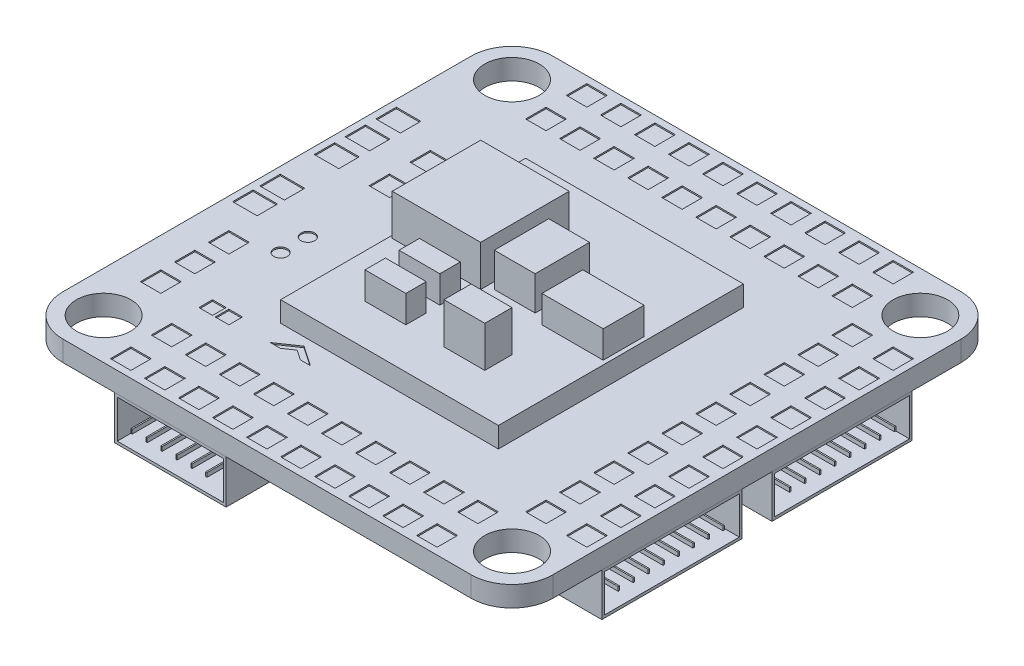
from build123d import *

# Parameters (mm, degrees)
SKETCH1_R                = 2
BOSS_EXTRUDE1_DEPTH      = 1.5
SKETCH2_W                = 16
SKETCH2_H                = 18
BOSS_EXTRUDE2_DEPTH      = 1.5
SKETCH3_W                = 6.5
SKETCH3_H                = 6.5
BOSS_EXTRUDE3_DEPTH      = 3
SKETCH4_W                = 3
SKETCH4_H                = 1.5
BOSS_EXTRUDE4_DEPTH      = 2
SKETCH5_W                = 3
SKETCH5_H                = 2
BOSS_EXTRUDE5_DEPTH      = 3
SKETCH6_W                = 3
SKETCH6_H                = 4
BOSS_EXTRUDE6_DEPTH      = 2.5
SKETCH7_W                = 4.5
SKETCH7_H                = 3
BOSS_EXTRUDE7_DEPTH      = 2
CUT_EXTRUDE1_DEPTH       = 0.1
SKETCH9_R                = 0.5
SKETCH9_W                = 1.5
SKETCH9_H                = 1.5
SKETCH9_W_2              = 1
SKETCH9_H_2              = 1
SKETCH9_W_3              = 1.8
CUT_EXTRUDE2_DEPTH       = 0.1
BOSS_EXTRUDE8_DEPTH      = 1.5
BOSS_EXTRUDE8_DEPTH_BACK = 5.7
CUT_EXTRUDE3_DEPTH       = 6
SKETCH15_W               = 2.5
SKETCH15_H               = 4.5
BOSS_EXTRUDE9_DEPTH      = 2
SKETCH16_W               = 2
SKETCH16_H               = 1
BOSS_EXTRUDE10_DEPTH     = 1
SKETCH17_W               = 8.2
SKETCH17_H               = 3.2
BOSS_EXTRUDE11_DEPTH     = 4.5
SKETCH18_W               = 7.8
SKETCH18_H               = 2.8
SKETCH18_W_2             = 0.1
SKETCH18_H_2             = 0.3
CUT_EXTRUDE4_DEPTH       = 4
SKETCH19_W               = 10.3
SKETCH19_H               = 3.1557765
BOSS_EXTRUDE12_DEPTH     = 4.3
BOSS_EXTRUDE12_2_DEPTH   = 4.3
SKETCH20_W               = 9.9
SKETCH20_H               = 2.7557765
SKETCH20_W_2             = 0.1
SKETCH20_H_2             = 0.3
CUT_EXTRUDE5_DEPTH       = 3.5


with BuildPart() as part:
    # Sketch1 → Boss-Extrude1 (new body)
    with BuildSketch(Plane(origin=(0, 0, 0), x_dir=(1, 0, 0), z_dir=(0, 1, 0))):
        with BuildLine():
            Line((-15, 18), (15, 18))
            ThreePointArc((15, 18), (17.121320344, 17.121320344), (18, 15))
            Line((18, 15), (18, -15))
            ThreePointArc((18, -15), (17.121320344, -17.121320344), (15, -18))
            Line((15, -18), (-15, -18))
            ThreePointArc((-15, -18), (-17.121320344, -17.121320344), (-18, -15))
            Line((-18, -15), (-18, 15))
            ThreePointArc((-18, 15), (-17.121320344, 17.121320344), (-15, 18))
        make_face()
        with Locations((-15, 15)):
            Circle(SKETCH1_R, mode=Mode.SUBTRACT)
        with Locations((15, 15)):
            Circle(SKETCH1_R, mode=Mode.SUBTRACT)
        with Locations((15, -15)):
            Circle(SKETCH1_R, mode=Mode.SUBTRACT)
        with Locations((-15, -15)):
            Circle(SKETCH1_R, mode=Mode.SUBTRACT)
    extrude(amount=BOSS_EXTRUDE1_DEPTH)

    # Sketch2 → Boss-Extrude2 (add)
    with BuildSketch(Plane(origin=(0, 1.5, 0), x_dir=(1, 0, 0), z_dir=(0, 1, 0))):
        Rectangle(SKETCH2_W, SKETCH2_H)
    extrude(amount=BOSS_EXTRUDE2_DEPTH)

    # Sketch3 → Boss-Extrude3 (add)
    with BuildSketch(Plane(origin=(0, 3, 0), x_dir=(1, 0, 0), z_dir=(0, 1, 0))):
        with Locations((-4.55, 2.25)):
            Rectangle(SKETCH3_W, SKETCH3_H)
    extrude(amount=BOSS_EXTRUDE3_DEPTH)

    # Sketch4 → Boss-Extrude4 (add)
    with BuildSketch(Plane(origin=(0, 3, 0), x_dir=(1, 0, 0), z_dir=(0, 1, 0))):
        with Locations((-3.3, -2.75)):
            Rectangle(SKETCH4_W, SKETCH4_H)
        with Locations((-3.3, -5.25)):
            Rectangle(SKETCH4_W, SKETCH4_H)
    extrude(amount=BOSS_EXTRUDE4_DEPTH)

    # Sketch5 → Boss-Extrude5 (add)
    with BuildSketch(Plane(origin=(0, 3, 0), x_dir=(1, 0, 0), z_dir=(0, 1, 0))):
        with Locations((2.5, -5)):
            Rectangle(SKETCH5_W, SKETCH5_H)
    extrude(amount=BOSS_EXTRUDE5_DEPTH)

    # Sketch6 → Boss-Extrude6 (add)
    with BuildSketch(Plane(origin=(0, 3, 0), x_dir=(1, 0, 0), z_dir=(0, 1, 0))):
        with Locations((0.7, 1.5)):
            Rectangle(SKETCH6_W, SKETCH6_H)
    extrude(amount=BOSS_EXTRUDE6_DEPTH)

    # Sketch7 → Boss-Extrude7 (add)
    with BuildSketch(Plane(origin=(0, 3, 0), x_dir=(1, 0, 0), z_dir=(0, 1, 0))):
        with Locations((5.45, 0.5)):
            Rectangle(SKETCH7_W, SKETCH7_H)
    extrude(amount=BOSS_EXTRUDE7_DEPTH)

    # Sketch8 → Cut-Extrude1 (cut)
    with BuildSketch(Plane(origin=(0, 1.5, 0), x_dir=(1, 0, 0), z_dir=(0, 1, 0))):
        Polygon((-5.680877994, -9.594371723), (-7.153698214, -10.604305588), (-6.417288104, -10.604305588), (-5.680877994, -10.099338656), (-4.944467883, -10.604305588), (-4.208057773, -10.604305588), align=None)
    extrude(amount=-CUT_EXTRUDE1_DEPTH, mode=Mode.SUBTRACT)

    # Sketch9 → Cut-Extrude2 (cut)
    with BuildSketch(Plane(origin=(0, 1.5, 0), x_dir=(1, 0, 0), z_dir=(0, 1, 0))):
        with Locations((-12.5, -4.5)):
            Circle(SKETCH9_R)
        with Locations((-12.5, -2.5)):
            Circle(SKETCH9_R)
        with Locations((-11.25, -13.75)):
            Rectangle(SKETCH9_W, SKETCH9_H)
        with Locations((-8.75, -13.75)):
            Rectangle(SKETCH9_W, SKETCH9_H)
        with Locations((-6.25, -13.75)):
            Rectangle(SKETCH9_W, SKETCH9_H)
        with Locations((-3.75, -13.75)):
            Rectangle(SKETCH9_W, SKETCH9_H)
        with Locations((-1.25, -13.75)):
            Rectangle(SKETCH9_W, SKETCH9_H)
        with Locations((1.25, -13.75)):
            Rectangle(SKETCH9_W, SKETCH9_H)
        with Locations((3.75, -13.75)):
            Rectangle(SKETCH9_W, SKETCH9_H)
        with Locations((6.25, -13.75)):
            Rectangle(SKETCH9_W, SKETCH9_H)
        with Locations((8.75, -13.75)):
            Rectangle(SKETCH9_W, SKETCH9_H)
        with Locations((11.25, -13.75)):
            Rectangle(SKETCH9_W, SKETCH9_H)
        with Locations((-8.75, -16.75)):
            Rectangle(SKETCH9_W, SKETCH9_H)
        with Locations((-6.25, -16.75)):
            Rectangle(SKETCH9_W, SKETCH9_H)
        with Locations((-3.75, -16.75)):
            Rectangle(SKETCH9_W, SKETCH9_H)
        with Locations((-1.25, -16.75)):
            Rectangle(SKETCH9_W, SKETCH9_H)
        with Locations((1.25, -16.75)):
            Rectangle(SKETCH9_W, SKETCH9_H)
        with Locations((3.75, -16.75)):
            Rectangle(SKETCH9_W, SKETCH9_H)
        with Locations((6.25, -16.75)):
            Rectangle(SKETCH9_W, SKETCH9_H)
        with Locations((8.75, -16.75)):
            Rectangle(SKETCH9_W, SKETCH9_H)
        with Locations((11.25, -16.75)):
            Rectangle(SKETCH9_W, SKETCH9_H)
        with Locations((-11.25, -16.75)):
            Rectangle(SKETCH9_W, SKETCH9_H)
        with Locations((16.75, 11.25)):
            Rectangle(SKETCH9_W, SKETCH9_H)
        with Locations((16.75, -11.25)):
            Rectangle(SKETCH9_W, SKETCH9_H)
        with Locations((16.75, -8.75)):
            Rectangle(SKETCH9_W, SKETCH9_H)
        with Locations((16.75, -6.25)):
            Rectangle(SKETCH9_W, SKETCH9_H)
        with Locations((16.75, -3.75)):
            Rectangle(SKETCH9_W, SKETCH9_H)
        with Locations((16.75, -1.25)):
            Rectangle(SKETCH9_W, SKETCH9_H)
        with Locations((16.75, 1.25)):
            Rectangle(SKETCH9_W, SKETCH9_H)
        with Locations((16.75, 3.75)):
            Rectangle(SKETCH9_W, SKETCH9_H)
        with Locations((16.75, 6.25)):
            Rectangle(SKETCH9_W, SKETCH9_H)
        with Locations((16.75, 8.75)):
            Rectangle(SKETCH9_W, SKETCH9_H)
        with Locations((13.75, -11.25)):
            Rectangle(SKETCH9_W, SKETCH9_H)
        with Locations((13.75, -8.75)):
            Rectangle(SKETCH9_W, SKETCH9_H)
        with Locations((13.75, -6.25)):
            Rectangle(SKETCH9_W, SKETCH9_H)
        with Locations((13.75, -3.75)):
            Rectangle(SKETCH9_W, SKETCH9_H)
        with Locations((13.75, -1.25)):
            Rectangle(SKETCH9_W, SKETCH9_H)
        with Locations((13.75, 1.25)):
            Rectangle(SKETCH9_W, SKETCH9_H)
        with Locations((13.75, 3.75)):
            Rectangle(SKETCH9_W, SKETCH9_H)
        with Locations((13.75, 6.25)):
            Rectangle(SKETCH9_W, SKETCH9_H)
        with Locations((13.75, 8.75)):
            Rectangle(SKETCH9_W, SKETCH9_H)
        with Locations((13.75, 11.25)):
            Rectangle(SKETCH9_W, SKETCH9_H)
        with Locations((-11.25, 16.75)):
            Rectangle(SKETCH9_W, SKETCH9_H)
        with Locations((11.25, 16.75)):
            Rectangle(SKETCH9_W, SKETCH9_H)
        with Locations((8.75, 16.75)):
            Rectangle(SKETCH9_W, SKETCH9_H)
        with Locations((6.25, 16.75)):
            Rectangle(SKETCH9_W, SKETCH9_H)
        with Locations((3.75, 16.75)):
            Rectangle(SKETCH9_W, SKETCH9_H)
        with Locations((1.25, 16.75)):
            Rectangle(SKETCH9_W, SKETCH9_H)
        with Locations((-1.25, 16.75)):
            Rectangle(SKETCH9_W, SKETCH9_H)
        with Locations((-3.75, 16.75)):
            Rectangle(SKETCH9_W, SKETCH9_H)
        with Locations((-6.25, 16.75)):
            Rectangle(SKETCH9_W, SKETCH9_H)
        with Locations((-8.75, 16.75)):
            Rectangle(SKETCH9_W, SKETCH9_H)
        with Locations((11.25, 13.75)):
            Rectangle(SKETCH9_W, SKETCH9_H)
        with Locations((8.75, 13.75)):
            Rectangle(SKETCH9_W, SKETCH9_H)
        with Locations((6.25, 13.75)):
            Rectangle(SKETCH9_W, SKETCH9_H)
        with Locations((3.75, 13.75)):
            Rectangle(SKETCH9_W, SKETCH9_H)
        with Locations((1.25, 13.75)):
            Rectangle(SKETCH9_W, SKETCH9_H)
        with Locations((-1.25, 13.75)):
            Rectangle(SKETCH9_W, SKETCH9_H)
        with Locations((-3.75, 13.75)):
            Rectangle(SKETCH9_W, SKETCH9_H)
        with Locations((-6.25, 13.75)):
            Rectangle(SKETCH9_W, SKETCH9_H)
        with Locations((-8.75, 13.75)):
            Rectangle(SKETCH9_W, SKETCH9_H)
        with Locations((-11.25, 13.75)):
            Rectangle(SKETCH9_W, SKETCH9_H)
        with Locations((-10.3, -10.5)):
            Rectangle(SKETCH9_W_2, SKETCH9_H_2)
        with Locations((-11.5, -10.5)):
            Rectangle(SKETCH9_W_2, SKETCH9_H_2)
        with Locations((-16.6, 8.25)):
            Rectangle(SKETCH9_W_3, SKETCH9_H)
        with Locations((-16.6, 5.987272692)):
            Rectangle(SKETCH9_W_3, SKETCH9_H)
        with Locations((-16.6, 3.724545384)):
            Rectangle(SKETCH9_W_3, SKETCH9_H)
        with Locations((-16.6, -2.275454616)):
            Rectangle(SKETCH9_W_3, SKETCH9_H)
        with Locations((-16.6, -0.275454616)):
            Rectangle(SKETCH9_W_3, SKETCH9_H)
        with Locations((-12.75, 3.75)):
            Rectangle(SKETCH9_W, SKETCH9_H)
        with Locations((-12.75, 6.75)):
            Rectangle(SKETCH9_W, SKETCH9_H)
        with Locations((-15.05, -8.25)):
            Rectangle(SKETCH9_W, SKETCH9_H)
        with Locations((-15.05, -10.75)):
            Rectangle(SKETCH9_W, SKETCH9_H)
        with Locations((-15.05, -5.75)):
            Rectangle(SKETCH9_W, SKETCH9_H)
    extrude(amount=-CUT_EXTRUDE2_DEPTH, mode=Mode.SUBTRACT)

    # Sketch12 → Boss-Extrude8 (add, two sides)
    with BuildSketch(Plane.ZY.offset(18)) as boss_extrude8_sk:
        with BuildLine():
            Line((-8.7, 0), (-3.1, 0))
            ThreePointArc((-3.1, 0), (-1.5, -1.6), (-3.1, -3.2))
            Line((-3.1, -3.2), (-8.7, -3.2))
            ThreePointArc((-8.7, -3.2), (-10.3, -1.6), (-8.7, 0))
        make_face()
    extrude(amount=BOSS_EXTRUDE8_DEPTH)
    extrude(boss_extrude8_sk.sketch, amount=-BOSS_EXTRUDE8_DEPTH_BACK)

    # Sketch13 → Cut-Extrude3 (cut)
    with BuildSketch(Plane.ZY.offset(19.5)):
        with BuildLine():
            ThreePointArc((-3.1, -0.1), (-1.6, -1.6), (-3.1, -3.1))
            Line((-3.1, -3.1), (-8.7, -3.1))
            ThreePointArc((-8.7, -3.1), (-10.2, -1.6), (-8.7, -0.1))
            Line((-8.7, -0.1), (-3.1, -0.1))
        make_face()
        with BuildLine():
            Line((-8.7, -1.8), (-3.1, -1.8))
            ThreePointArc((-3.1, -1.8), (-2.9, -1.6), (-3.1, -1.4))
            Line((-3.1, -1.4), (-8.7, -1.4))
            ThreePointArc((-8.7, -1.4), (-8.9, -1.6), (-8.7, -1.8))
        make_face(mode=Mode.SUBTRACT)
    extrude(amount=-CUT_EXTRUDE3_DEPTH, mode=Mode.SUBTRACT)

    # Sketch15 → Boss-Extrude9 (add)
    with BuildSketch(Plane.XZ):
        with Locations((-16.45, 7.25)):
            Rectangle(SKETCH15_W, SKETCH15_H)
    extrude(amount=BOSS_EXTRUDE9_DEPTH)

    # Sketch16 → Boss-Extrude10 (add)
    with BuildSketch(Plane.ZY.offset(17.7)):
        with Locations((7.25, -1)):
            Rectangle(SKETCH16_W, SKETCH16_H)
    extrude(amount=BOSS_EXTRUDE10_DEPTH)


with BuildPart() as body_2:
    # Sketch17 → Boss-Extrude11 (new body)
    with BuildSketch(Plane.XY.offset(18)):
        with Locations((-7.1, -1.6)):
            Rectangle(SKETCH17_W, SKETCH17_H)
    extrude(amount=-BOSS_EXTRUDE11_DEPTH)

    # Sketch18 → Cut-Extrude4 (cut)
    with BuildSketch(Plane.XY.offset(18)):
        with Locations((-7.1, -1.6)):
            Rectangle(SKETCH18_W, SKETCH18_H)
        with Locations((-4.45, -1.85)):
            Rectangle(SKETCH18_W_2, SKETCH18_H_2, mode=Mode.SUBTRACT)
        with Locations((-5.55, -1.85)):
            Rectangle(SKETCH18_W_2, SKETCH18_H_2, mode=Mode.SUBTRACT)
        with Locations((-6.65, -1.85)):
            Rectangle(SKETCH18_W_2, SKETCH18_H_2, mode=Mode.SUBTRACT)
        with Locations((-7.75, -1.85)):
            Rectangle(SKETCH18_W_2, SKETCH18_H_2, mode=Mode.SUBTRACT)
        with Locations((-8.85, -1.85)):
            Rectangle(SKETCH18_W_2, SKETCH18_H_2, mode=Mode.SUBTRACT)
        with Locations((-9.95, -1.85)):
            Rectangle(SKETCH18_W_2, SKETCH18_H_2, mode=Mode.SUBTRACT)
    extrude(amount=-CUT_EXTRUDE4_DEPTH, mode=Mode.SUBTRACT)


with BuildPart() as body_3:
    # Sketch19 → Boss-Extrude12 (new body)
    with BuildSketch(Plane(origin=(18, 0, 0), x_dir=(0, 0, -1), z_dir=(1, 0, 0))):
        with Locations((-6.25, -1.57788825)):
            Rectangle(SKETCH19_W, SKETCH19_H)
    extrude(amount=-BOSS_EXTRUDE12_DEPTH)


with BuildPart() as body_4:
    # Sketch19 → Boss-Extrude12 2 (new body)
    with BuildSketch(Plane(origin=(18, 0, 0), x_dir=(0, 0, -1), z_dir=(1, 0, 0))):
        with Locations((6.25, -1.57788825)):
            Rectangle(SKETCH19_W, SKETCH19_H)
    extrude(amount=-BOSS_EXTRUDE12_2_DEPTH)


with BuildPart() as cut_extrude5_tool:
    # Sketch20 → Cut-Extrude5 (new body)
    with BuildSketch(Plane(origin=(18, 0, 0), x_dir=(0, 0, -1), z_dir=(1, 0, 0))):
        with Locations((-6.25, -1.57788825)):
            Rectangle(SKETCH20_W, SKETCH20_H)
        with Locations((-2.45, -1.8057765)):
            Rectangle(SKETCH20_W_2, SKETCH20_H_2, mode=Mode.SUBTRACT)
        with Locations((-3.55, -1.8057765)):
            Rectangle(SKETCH20_W_2, SKETCH20_H_2, mode=Mode.SUBTRACT)
        with Locations((-4.65, -1.8057765)):
            Rectangle(SKETCH20_W_2, SKETCH20_H_2, mode=Mode.SUBTRACT)
        with Locations((-5.75, -1.8057765)):
            Rectangle(SKETCH20_W_2, SKETCH20_H_2, mode=Mode.SUBTRACT)
        with Locations((-6.85, -1.8057765)):
            Rectangle(SKETCH20_W_2, SKETCH20_H_2, mode=Mode.SUBTRACT)
        with Locations((-7.95, -1.8057765)):
            Rectangle(SKETCH20_W_2, SKETCH20_H_2, mode=Mode.SUBTRACT)
        with Locations((-9.05, -1.8057765)):
            Rectangle(SKETCH20_W_2, SKETCH20_H_2, mode=Mode.SUBTRACT)
        with Locations((-10.15, -1.8057765)):
            Rectangle(SKETCH20_W_2, SKETCH20_H_2, mode=Mode.SUBTRACT)
        with Locations((6.25, -1.57788825)):
            Rectangle(SKETCH20_W, SKETCH20_H)
        with Locations((10.15, -1.8057765)):
            Rectangle(SKETCH20_W_2, SKETCH20_H_2, mode=Mode.SUBTRACT)
        with Locations((2.45, -1.8057765)):
            Rectangle(SKETCH20_W_2, SKETCH20_H_2, mode=Mode.SUBTRACT)
        with Locations((3.55, -1.8057765)):
            Rectangle(SKETCH20_W_2, SKETCH20_H_2, mode=Mode.SUBTRACT)
        with Locations((4.65, -1.8057765)):
            Rectangle(SKETCH20_W_2, SKETCH20_H_2, mode=Mode.SUBTRACT)
        with Locations((5.75, -1.8057765)):
            Rectangle(SKETCH20_W_2, SKETCH20_H_2, mode=Mode.SUBTRACT)
        with Locations((6.85, -1.8057765)):
            Rectangle(SKETCH20_W_2, SKETCH20_H_2, mode=Mode.SUBTRACT)
        with Locations((7.95, -1.8057765)):
            Rectangle(SKETCH20_W_2, SKETCH20_H_2, mode=Mode.SUBTRACT)
        with Locations((9.05, -1.8057765)):
            Rectangle(SKETCH20_W_2, SKETCH20_H_2, mode=Mode.SUBTRACT)
    extrude(amount=-CUT_EXTRUDE5_DEPTH)


with BuildPart() as body_3_1:
    add(body_3.part)

    # Cut-Extrude5: cut by cut_extrude5_tool
    add(cut_extrude5_tool.part, mode=Mode.SUBTRACT)


with BuildPart() as body_4_1:
    add(body_4.part)

    # Cut-Extrude5: cut by cut_extrude5_tool
    add(cut_extrude5_tool.part, mode=Mode.SUBTRACT)


solid = Compound([part.part, body_2.part, body_3_1.part, body_4_1.part])
